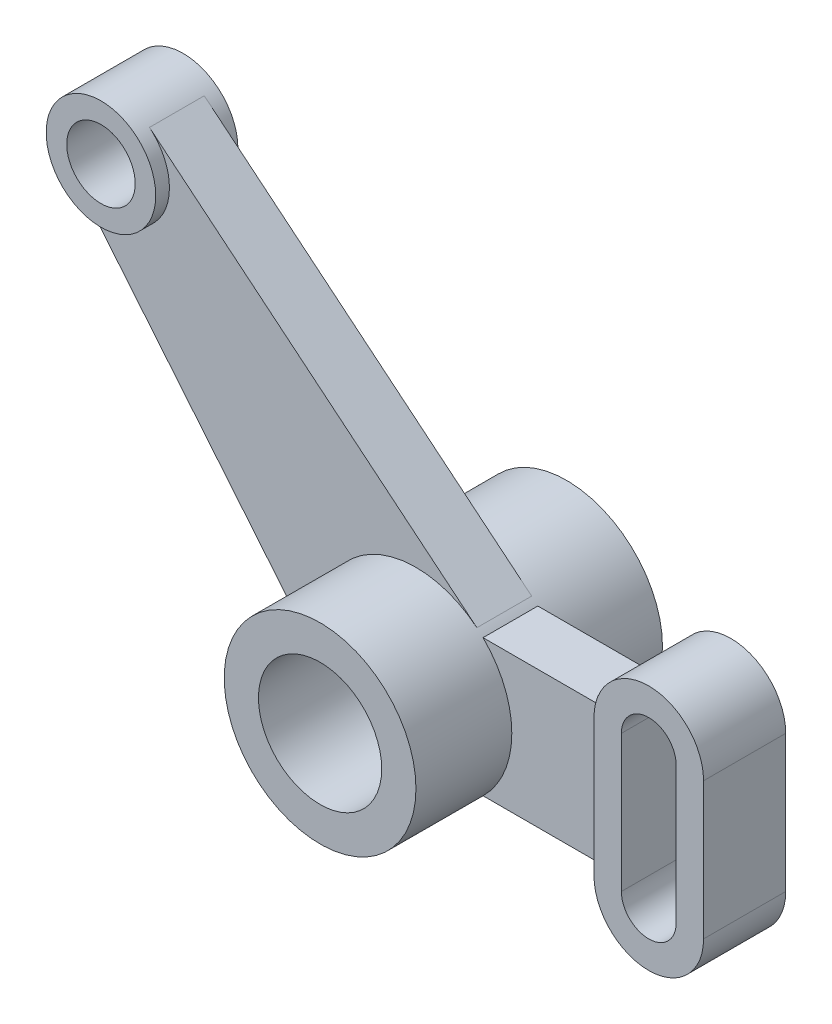
from build123d import *

# Parameters (mm, degrees)
ESBO_O2_R                  = 22.499999999999996
RESSALTO_EXTRUS_O1_DEPTH   = 45
RESSALTO_EXTRUS_O2_DEPTH   = 15
ESBO_O2_3_R                = 19.999999999999982
ESBO_O2_3_R_2              = 12.50000000000002
RESSALTO_EXTRUS_O2_2_DEPTH = 15
RESSALTO_EXTRUS_O4_DEPTH   = 10


with BuildPart() as part:
    # Esboço2 → Ressalto-extrusão1 (new, symmetric)
    with BuildSketch(Plane.XY):
        with BuildLine():
            ThreePointArc((-27.019781356912492, -22.24705408418482), (-1.8677359336065302, -34.95012964900582), (24.49489742783113, -25.000000000000647))
            ThreePointArc((24.49489742783113, -25.000000000000647), (32.26702194171388, -13.558735007844774), (35.00000000000001, -8.57e-15))
            ThreePointArc((35.00000000000001, 0), (32.267021941714255, 13.558735007843877), (24.494897427832516, 24.999999999999286))
            ThreePointArc((24.494897427832516, 24.999999999999286), (23.392784934043004, 26.034162422279138), (22.2470540841853, 27.019781356912098))
            ThreePointArc((22.2470540841853, 27.019781356912098), (-24.748737341528944, 24.74873734152939), (-27.019781356912492, -22.24705408418482))
        make_face()
        Circle(ESBO_O2_R, mode=Mode.SUBTRACT)
    extrude(amount=RESSALTO_EXTRUS_O1_DEPTH, both=True)



with BuildPart() as body_2:
    # Esboço2<3> → Ressalto-extrusão2 (new, symmetric)
    with BuildSketch(Plane.XY):
        with BuildLine():
            Line((69.99999999999999, 24.99999999999937), (70, -25.0000000000006))
            ThreePointArc((70, -25.0000000000006), (90, -45.00000000000057), (110, -25.00000000000059))
            Line((109.99999999999999, -25.00000000000059), (109.99999999999999, 24.999999999999396))
            ThreePointArc((109.99999999999997, 24.999999999999392), (89.99999999999997, 44.999999999999424), (69.99999999999997, 24.99999999999938))
        make_face()
        with BuildLine():
            ThreePointArc((100, -25.000000000000597), (90, -35.00000000000057), (80, -25.000000000000597))
            Line((80, -25.000000000000597), (79.99999999999999, 24.999999999999375))
            ThreePointArc((79.99999999999997, 24.99999999999938), (89.99999999999996, 34.99999999999941), (99.99999999999997, 24.999999999999407))
            Line((99.99999999999997, 24.999999999999407), (99.99999999999999, -25.000000000000593))
        make_face(mode=Mode.SUBTRACT)
    extrude(amount=RESSALTO_EXTRUS_O2_DEPTH, both=True)


with BuildPart() as body_3:
    # Esboço2<3> → Ressalto-extrus_o2 2 (new, symmetric)
    with BuildSketch(Plane.XY):
        with Locations((-110, 110.00000000000196)):
            Circle(ESBO_O2_3_R)
        with Locations((-110.00000000000001, 110.00000000000196)):
            Circle(ESBO_O2_3_R_2, mode=Mode.SUBTRACT)
    extrude(amount=RESSALTO_EXTRUS_O2_2_DEPTH, both=True)


with BuildPart() as part_1:
    add(part.part)

    add(body_3.part)  # Ressalto-extrusão4 merges body 3
    # Esboço2<5> → Ressalto-extrusão4 (add, symmetric)
    with BuildSketch(Plane.XY):
        with BuildLine():
            Line((24.49489742783112, -25.000000000000647), (70, -25.0000000000006))
            Line((70, -25.0000000000006), (69.99999999999999, 24.99999999999937))
            Line((69.99999999999999, 24.999999999999375), (24.494897427832516, 24.999999999999286))
            ThreePointArc((24.494897427832516, 24.999999999999286), (35.000000000000014, -9.77e-13), (24.49489742783112, -25.000000000000654))
        make_face()
        with BuildLine():
            Line((-125.43987506109286, 97.28739766618204), (-27.019781356912475, -22.24705408418481))
            ThreePointArc((-27.019781356912492, -22.24705408418482), (-24.748737341528944, 24.74873734152939), (22.2470540841853, 27.019781356912098))
            Line((22.247054084185294, 27.019781356912105), (-97.28739766617986, 125.43987506109455))
            ThreePointArc((-97.28739766617984, 125.43987506109457), (-95.85786437626919, 95.8578643762709), (-125.43987506109285, 97.28739766618206))
        make_face()
    extrude(amount=RESSALTO_EXTRUS_O4_DEPTH, both=True)


solid = Compound([body_2.part, part_1.part])
